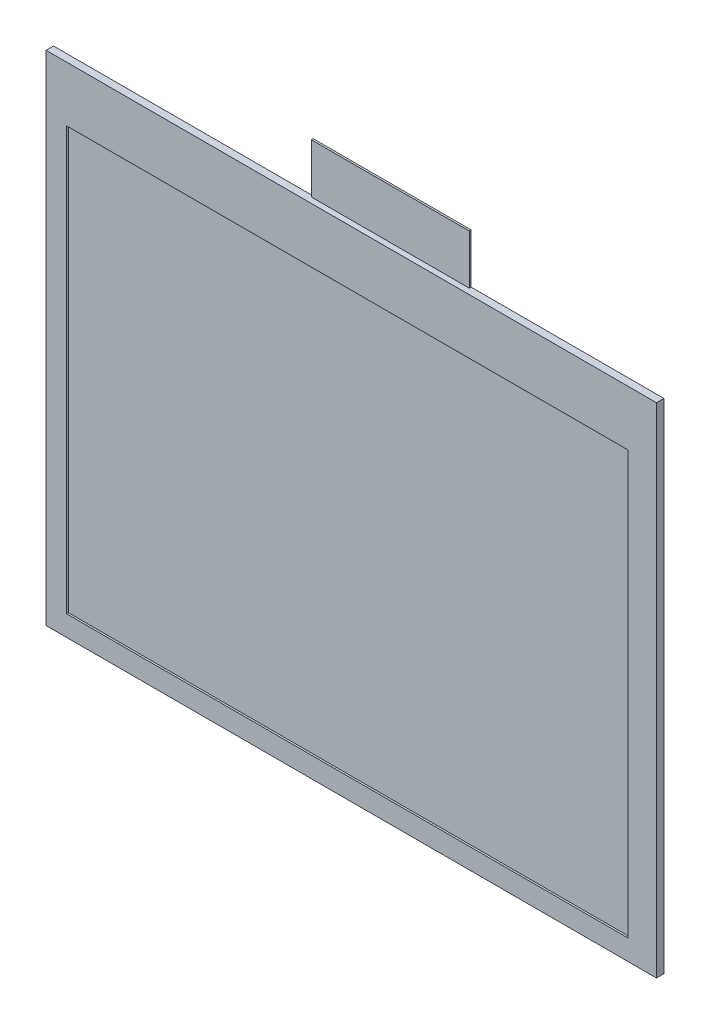
from build123d import *

# Parameters (mm, degrees)
SKETCH1_W           = 90.6
SKETCH1_H           = 68.2
BOSS_EXTRUDE1_DEPTH = 1.2
SKETCH1_3_W         = 90.6
SKETCH1_3_H         = 68.2
BOSS_EXTRUDE2_DEPTH = 0.9
SKETCH1_4_W         = 25.5
SKETCH1_4_H         = 8
BOSS_EXTRUDE3_DEPTH = 0.3


with BuildPart() as part:
    # Sketch1 → Boss-Extrude1 (new body)
    with BuildSketch(Plane.XY):
        Polygon((-48.6, 43), (-48.6, -37.4), (49.9, -37.4), (49.9, 43), (18.8, 43), (-6.7, 43), align=None)
        Rectangle(SKETCH1_W, SKETCH1_H, mode=Mode.SUBTRACT)
    extrude(amount=BOSS_EXTRUDE1_DEPTH)

    # Sketch1_3 → Boss-Extrude2 (add)
    with BuildSketch(Plane.XY):
        Rectangle(SKETCH1_3_W, SKETCH1_3_H)
    extrude(amount=BOSS_EXTRUDE2_DEPTH)

    # Sketch1_4 → Boss-Extrude3 (add)
    with BuildSketch(Plane.XY):
        with Locations((6.05, 47)):
            Rectangle(SKETCH1_4_W, SKETCH1_4_H)
    extrude(amount=BOSS_EXTRUDE3_DEPTH)


solid = part.part
